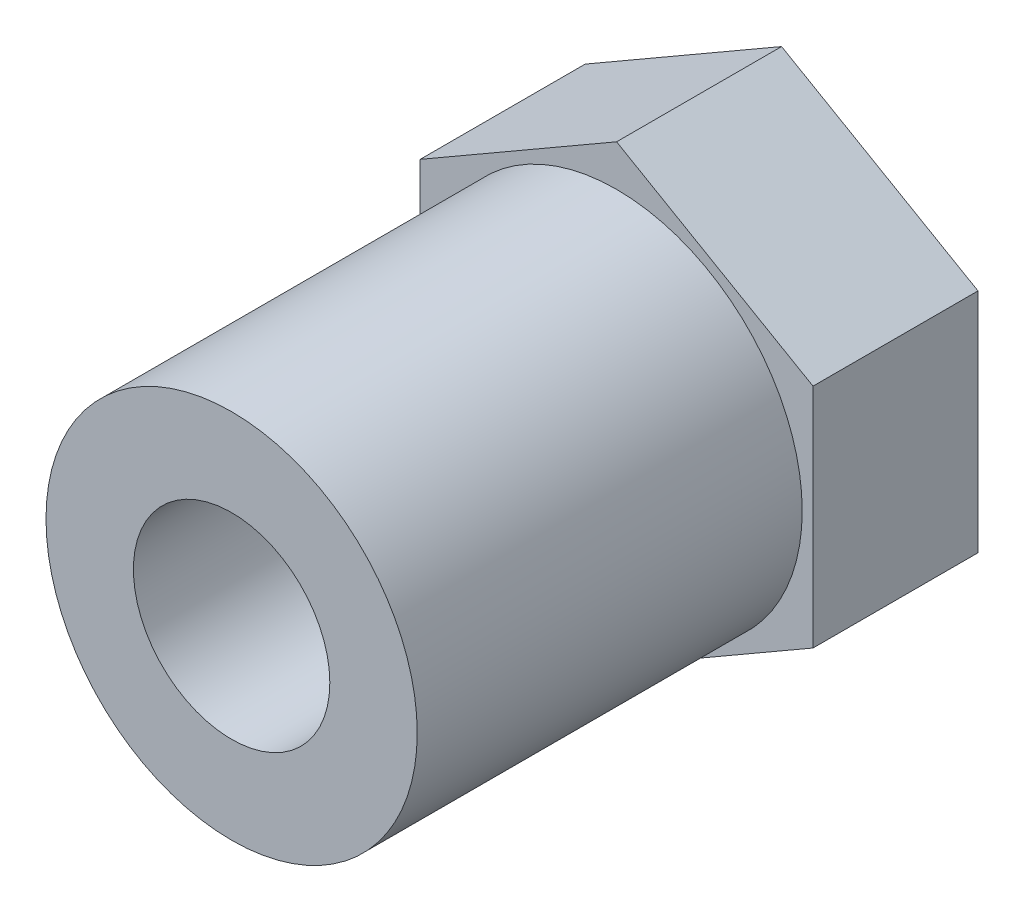
from build123d import *

# Parameters (mm, degrees)
SKETCH1_R           = 2.5
BOSS_EXTRUDE1_DEPTH = 4.2
SKETCH2_R           = 4.725
SKETCH2_R_2         = 2.5
BOSS_EXTRUDE2_DEPTH = 9.8


with BuildPart() as part:
    # Sketch1 → Boss-Extrude1 (new body)
    with BuildSketch(Plane.XY):
        Polygon((5, 2.886751346), (0, 5.773502692), (-5, 2.886751346), (-5, -2.886751346), (0, -5.773502692), (5, -2.886751346), align=None)
        Circle(SKETCH1_R, mode=Mode.SUBTRACT)
    extrude(amount=BOSS_EXTRUDE1_DEPTH)

    # Sketch2 → Boss-Extrude2 (add)
    with BuildSketch(Plane.XY.offset(4.2)):
        Circle(SKETCH2_R)
        Circle(SKETCH2_R_2, mode=Mode.SUBTRACT)
    extrude(amount=BOSS_EXTRUDE2_DEPTH)


solid = part.part
